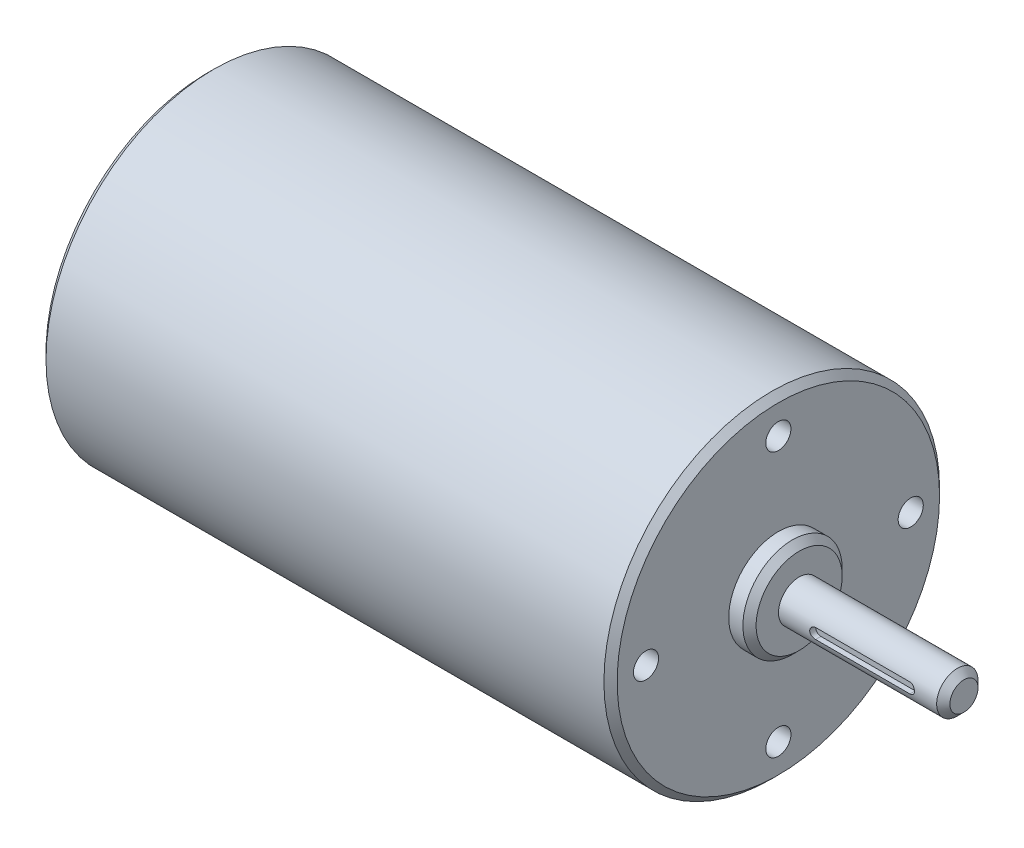
from build123d import *

# Parameters (mm, degrees)
SKETCH2_R           = 32.2072
BOSS_EXTRUDE1_DEPTH = 109.601
CHAMFER1_SIZE       = 1.27
CHAMFER2_SIZE       = 1.27
SKETCH3_R           = 9.525
BOSS_EXTRUDE2_DEPTH = 3.9878
SKETCH4_R           = 3.96875
BOSS_EXTRUDE3_DEPTH = 31.623
CHAMFER3_SIZE       = 1.27
CHAMFER4_SIZE       = 1.27
SKETCH5_R           = 15.24
BOSS_EXTRUDE4_DEPTH = 3.9878
CHAMFER5_SIZE       = 1.27
CUT_EXTRUDE1_DEPTH  = 1.15062
SKETCH7_R           = 2.413
CUT_EXTRUDE2_DEPTH  = 6.35


with BuildPart() as part:
    # Sketch2 → Boss-Extrude1 (new body)
    with BuildSketch(Plane(origin=(0, 0, 0), x_dir=(0, 0, -1), z_dir=(1, 0, 0))):
        Circle(SKETCH2_R)
    extrude(amount=BOSS_EXTRUDE1_DEPTH)

    # Chamfer1
    chamfer1_edges = [part.edges().sort_by_distance(p)[0] for p in [
        (0, 0, 32.2072),
    ]]
    chamfer(chamfer1_edges, length=CHAMFER1_SIZE)

    # Chamfer2
    chamfer2_edges = [part.edges().sort_by_distance(p)[0] for p in [
        (109.601, 0, 32.2072),
    ]]
    chamfer(chamfer2_edges, length=CHAMFER2_SIZE)

    # Sketch3 → Boss-Extrude2 (add)
    with BuildSketch(Plane(origin=(109.601, 0, 0), x_dir=(0, 0, -1), z_dir=(1, 0, 0))):
        Circle(SKETCH3_R)
    extrude(amount=BOSS_EXTRUDE2_DEPTH)

    # Sketch4 → Boss-Extrude3 (add)
    with BuildSketch(Plane(origin=(113.5888, 0, 0), x_dir=(0, 0, -1), z_dir=(1, 0, 0))):
        Circle(SKETCH4_R)
    extrude(amount=BOSS_EXTRUDE3_DEPTH)

    # Chamfer3
    chamfer3_edges = [part.edges().sort_by_distance(p)[0] for p in [
        (113.5888, 0, 9.525),
    ]]
    chamfer(chamfer3_edges, length=CHAMFER3_SIZE)

    # Chamfer4
    chamfer4_edges = [part.edges().sort_by_distance(p)[0] for p in [
        (145.2118, 0, 3.96875),
    ]]
    chamfer(chamfer4_edges, length=CHAMFER4_SIZE)

    # Sketch5 → Boss-Extrude4 (add)
    with BuildSketch(Plane.ZY):
        Circle(SKETCH5_R)
    extrude(amount=BOSS_EXTRUDE4_DEPTH)

    # Chamfer5
    chamfer5_edges = [part.edges().sort_by_distance(p)[0] for p in [
        (-3.9878, 0, -15.24),
    ]]
    chamfer(chamfer5_edges, length=CHAMFER5_SIZE)

    # Sketch6 → Cut-Extrude1 (cut)
    with BuildSketch(Plane.XY.offset(3.96875)):
        with BuildLine():
            Line((120.58269, 0.99949), (138.68273, 0.99949))
            ThreePointArc((138.68273, 0.99949), (139.68222, 0), (138.68273, -0.99949))
            Line((138.68273, -0.99949), (120.58269, -0.99949))
            ThreePointArc((120.58269, -0.99949), (119.5832, 0), (120.58269, 0.99949))
        make_face()
    extrude(amount=-CUT_EXTRUDE1_DEPTH, mode=Mode.SUBTRACT)

    # Sketch7 → Cut-Extrude2 (cut)
    with BuildSketch(Plane(origin=(109.601, 0, 0), x_dir=(0, 0, -1), z_dir=(1, 0, 0))):
        with Locations((0, 25.4)):
            Circle(SKETCH7_R)
        with Locations((25.4, 0)):
            Circle(SKETCH7_R)
        with Locations((0, -25.4)):
            Circle(SKETCH7_R)
        with Locations((-25.4, 0)):
            Circle(SKETCH7_R)
    extrude(amount=-CUT_EXTRUDE2_DEPTH, mode=Mode.SUBTRACT)


solid = part.part
